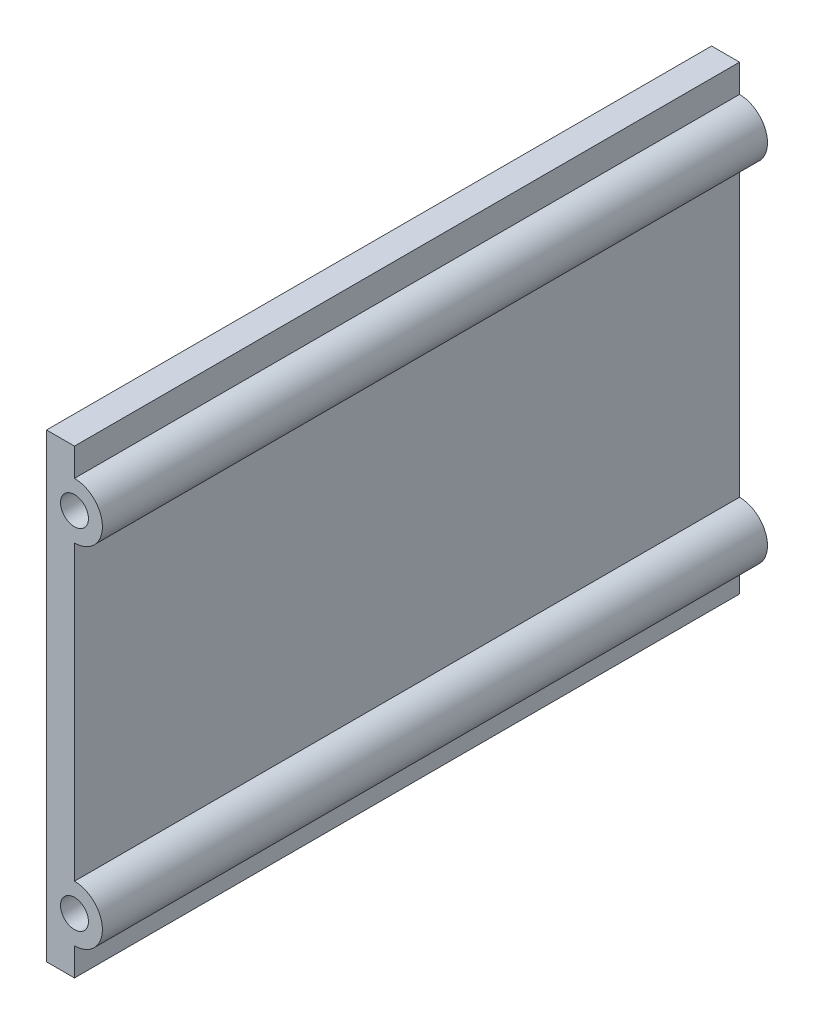
from build123d import *

# Parameters (mm, degrees)
SKETCH_1_R      = 2.5
EXTRUDE_1_DEPTH = 119


with BuildPart() as part:
    # 草图1 → 凸台-拉伸1 (new body)
    with BuildSketch(Plane.XY):
        with BuildLine():
            Line((-166.5, 31.210634294), (-166.5, -31.210634294))
            Line((-166.5, -31.210634294), (-166.5, -36.210634294))
            Line((-166.5, -36.210634294), (-166.5, -41.210634294))
            Line((-166.5, -41.210634294), (-161.5, -41.210634294))
            Line((-161.5, -41.210634294), (-161.5, -36.210634294))
            ThreePointArc((-161.5, -36.210634294), (-156.5, -31.210634294), (-161.5, -26.210634294))
            Line((-161.5, -26.210634294), (-161.5, 26.210634294))
            ThreePointArc((-161.5, 26.210634294), (-156.5, 31.210634294), (-161.5, 36.210634294))
            Line((-161.5, 36.210634294), (-161.5, 41.210634294))
            Line((-161.5, 41.210634294), (-166.5, 41.210634294))
            Line((-166.5, 41.210634294), (-166.5, 36.210634294))
            Line((-166.5, 36.210634294), (-166.5, 31.210634294))
        make_face()
        with Locations((-161.5, 31.210634294)):
            Circle(SKETCH_1_R, mode=Mode.SUBTRACT)
        with Locations((-161.5, -31.210634294)):
            Circle(SKETCH_1_R, mode=Mode.SUBTRACT)
    extrude(amount=EXTRUDE_1_DEPTH)


solid = part.part
